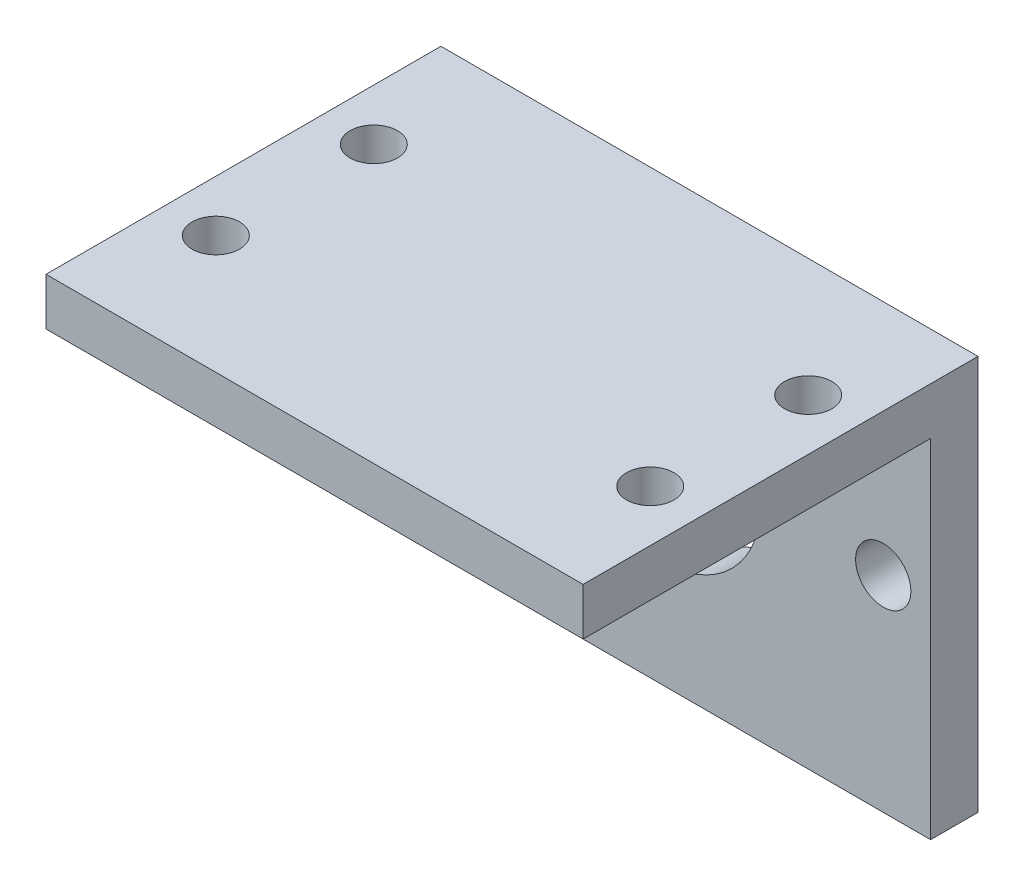
from build123d import *

# Parameters (mm, degrees)
SKETCH_1_W          = 68
SKETCH_1_H          = 50
SKETCH_1_R          = 3
EXTRUDE_1_DEPTH     = 6
SKETCH_3_W          = 68
SKETCH_3_H          = 6
EXTRUDE_2_DEPTH     = 50
CUT_EXTRUDE_1_REACH = 8
SKETCH_4_R          = 12.5
SKETCH_4_R_2        = 3.5


with BuildPart() as part:
    # 草图1 → 凸台-拉伸1 (new body)
    with BuildSketch(Plane(origin=(0, 0, 0), x_dir=(1, 0, 0), z_dir=(0, 1, 0))):
        with Locations((0, 25)):
            Rectangle(SKETCH_1_W, SKETCH_1_H)
        with Locations((-27.5, 35)):
            Circle(SKETCH_1_R, mode=Mode.SUBTRACT)
        with Locations((27.5, 35)):
            Circle(SKETCH_1_R, mode=Mode.SUBTRACT)
        with Locations((-27.5, 15)):
            Circle(SKETCH_1_R, mode=Mode.SUBTRACT)
        with Locations((27.5, 15)):
            Circle(SKETCH_1_R, mode=Mode.SUBTRACT)
    extrude(amount=EXTRUDE_1_DEPTH)

    # 草图3 → 凸台-拉伸2 (add)
    with BuildSketch(Plane(origin=(0, 6, 0), x_dir=(1, 0, 0), z_dir=(0, 1, 0))):
        with Locations((0, 47)):
            Rectangle(SKETCH_3_W, SKETCH_3_H)
    extrude(amount=-EXTRUDE_2_DEPTH)

    # 草图4 → 切除-拉伸1 (cut, up to next)
    with BuildSketch(Plane.XY.offset(-44), mode=Mode.PRIVATE) as cut_extrude_1_sk1:
        with Locations((0, -18)):
            Circle(SKETCH_4_R)
    cut_extrude_1_tool1 = extrude(cut_extrude_1_sk1.sketch, amount=-CUT_EXTRUDE_1_REACH, mode=Mode.PRIVATE) & part.part
    add(cut_extrude_1_tool1.solids().sort_by_distance((0, -18, -44))[0], mode=Mode.SUBTRACT)
    # 草图4 → 切除-拉伸1 (cut, up to next)
    with BuildSketch(Plane.XY.offset(-44), mode=Mode.PRIVATE) as cut_extrude_1_sk2:
        with Locations((28, -18)):
            Circle(SKETCH_4_R_2)
    cut_extrude_1_tool2 = extrude(cut_extrude_1_sk2.sketch, amount=-CUT_EXTRUDE_1_REACH, mode=Mode.PRIVATE) & part.part
    add(cut_extrude_1_tool2.solids().sort_by_distance((28, -18, -44))[0], mode=Mode.SUBTRACT)
    # 草图4 → 切除-拉伸1 (cut, up to next)
    with BuildSketch(Plane.XY.offset(-44), mode=Mode.PRIVATE) as cut_extrude_1_sk3:
        with Locations((-28, -18)):
            Circle(SKETCH_4_R_2)
    cut_extrude_1_tool3 = extrude(cut_extrude_1_sk3.sketch, amount=-CUT_EXTRUDE_1_REACH, mode=Mode.PRIVATE) & part.part
    add(cut_extrude_1_tool3.solids().sort_by_distance((-28, -18, -44))[0], mode=Mode.SUBTRACT)


solid = part.part
